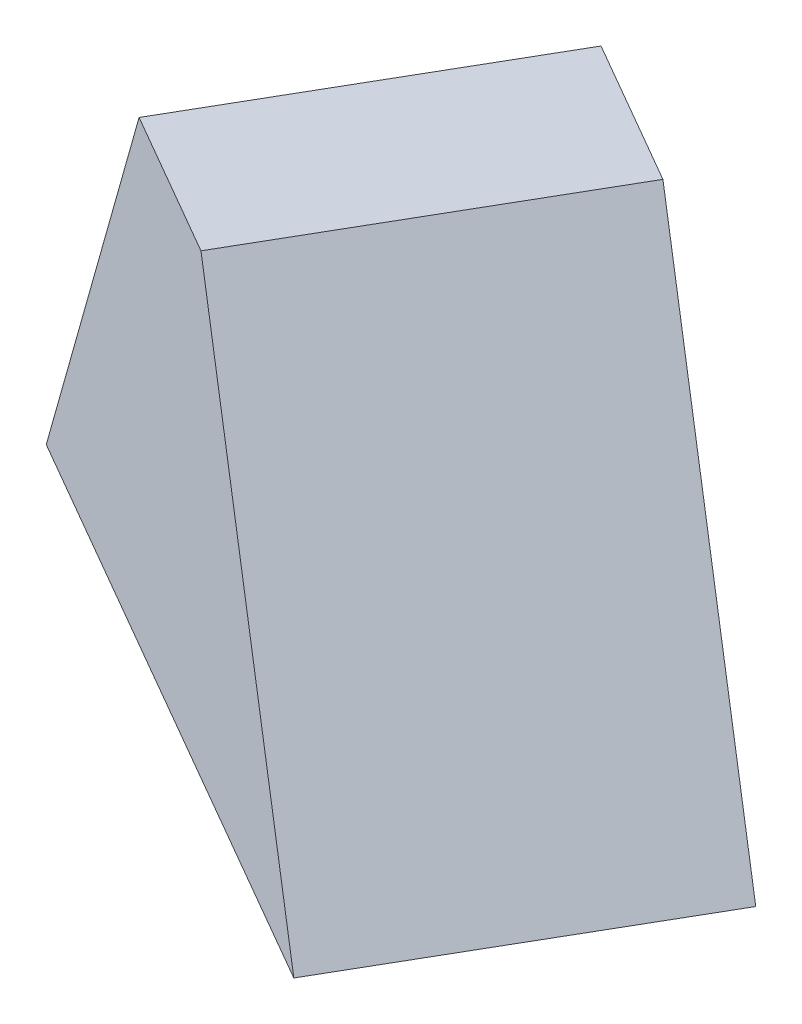
from build123d import *


with BuildPart() as part:
    # Sketch3 → Loft1 section 0
    with BuildSketch(Plane(origin=(0, 54, 0), x_dir=(-1, 0, 0), z_dir=(0, 1, 0))):
        Polygon((-14.076095526, 25), (5.923904474, 59.641016151), (-11.396603602, 69.641016151), (-31.396603602, 35), align=None)
    # Sketch1 → Loft1 section 1
    with BuildSketch(Plane(origin=(0, 0, 0), x_dir=(1, 0, 0), z_dir=(0, 1, 0))):
        Polygon((-11.904666587, -10), (-31.904666587, -44.641016151), (37.377365716, -84.641016151), (57.377365716, -50), align=None)
    loft()


solid = part.part
